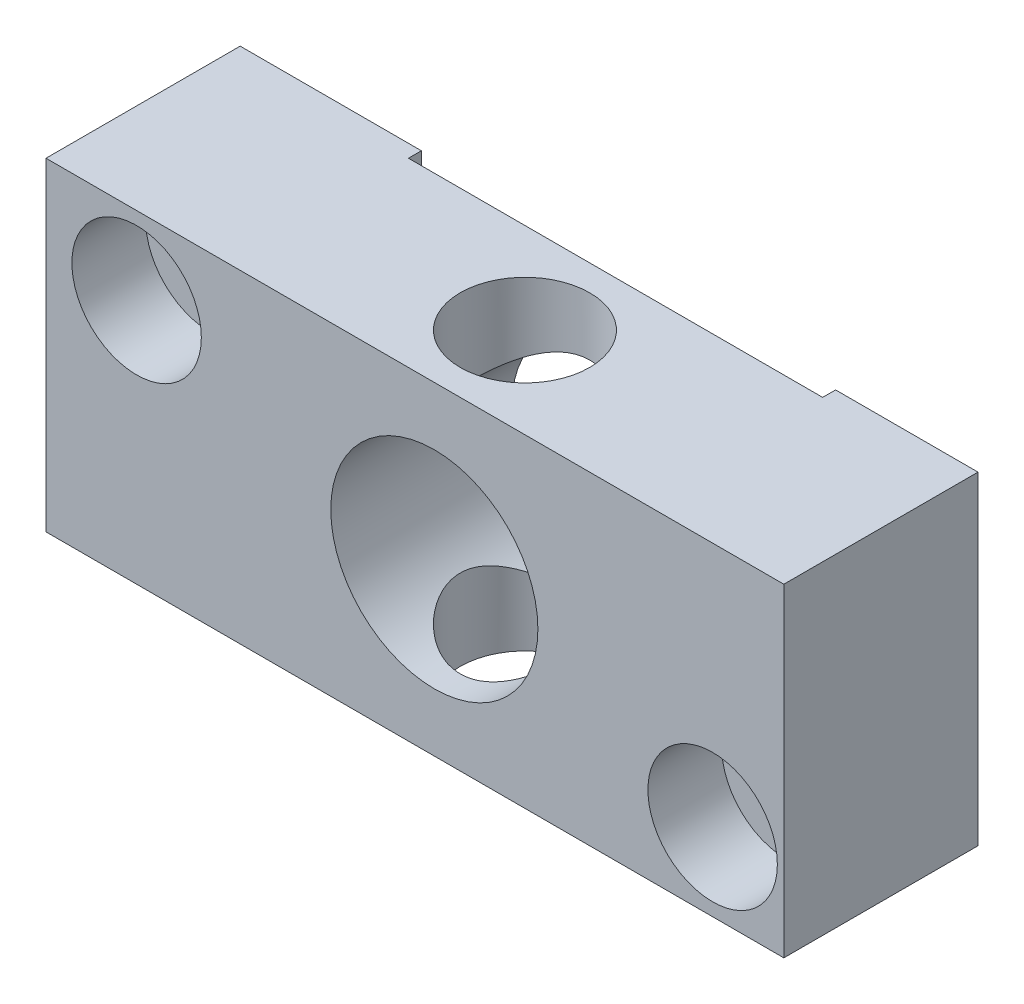
from build123d import *

# Parameters (mm, degrees)
SKETCH1_R           = 5
BOSS_EXTRUDE2_DEPTH = 25
SKETCH3_R           = 2.75
SKETCH3_R_2         = 8
CUT_EXTRUDE1_DEPTH  = 16
SKETCH4_R           = 5
CUT_EXTRUDE2_DEPTH  = 5.7


with BuildPart() as part:
    # Sketch1 → Boss-Extrude2 (new body)
    with BuildSketch(Plane(origin=(0, 0, 0), x_dir=(1, 0, 0), z_dir=(0, 1, 0))):
        Polygon((-14.5, 7.5), (-14.5, 6.5), (17.5, 6.5), (17.5, 7.5), (28.5, 7.5), (28.5, -7.5), (-28.5, -7.5), (-28.5, 7.5), align=None)
        with Locations((1.5, -0.5)):
            Circle(SKETCH1_R, mode=Mode.SUBTRACT)
    extrude(amount=BOSS_EXTRUDE2_DEPTH)

    # Sketch3 → Cut-Extrude1 (cut, through all)
    with BuildSketch(Plane.XY.offset(7.5)):
        with Locations((-21.5, 19)):
            Circle(SKETCH3_R)
        with Locations((1.5, 12.5)):
            Circle(SKETCH3_R_2)
        with Locations((23, 6)):
            Circle(SKETCH3_R)
    extrude(amount=-CUT_EXTRUDE1_DEPTH, mode=Mode.SUBTRACT)

    # Sketch4 → Cut-Extrude2 (cut)
    with BuildSketch(Plane.XY.offset(7.5)):
        with Locations((-21.5, 19)):
            Circle(SKETCH4_R)
        with Locations((23, 6)):
            Circle(SKETCH4_R)
    extrude(amount=-CUT_EXTRUDE2_DEPTH, mode=Mode.SUBTRACT)


solid = part.part
